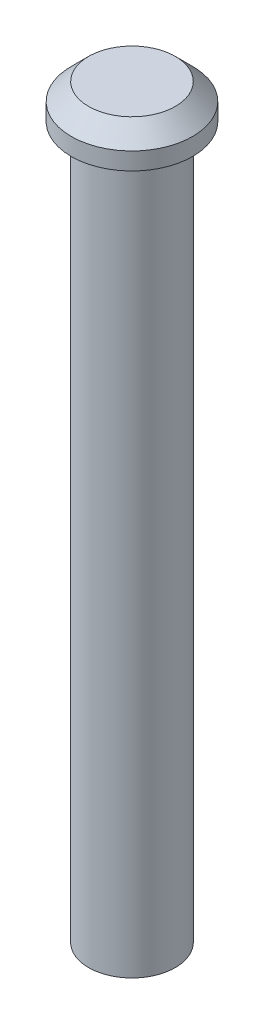
from build123d import *

# Parameters (mm, degrees)
SKETCH1_R           = 2.5
BOSS_EXTRUDE1_DEPTH = 41
SKETCH2_R           = 3.5
BOSS_EXTRUDE2_DEPTH = 2
CHAMFER1_SIZE       = 1
SKETCH3_R           = 1.5
CUT_EXTRUDE1_DEPTH  = 5


with BuildPart() as part:
    # Sketch1 → Boss-Extrude1 (new body)
    with BuildSketch(Plane(origin=(0, 0, 0), x_dir=(1, 0, 0), z_dir=(0, 1, 0))):
        Circle(SKETCH1_R)
    extrude(amount=BOSS_EXTRUDE1_DEPTH)

    # Sketch2 → Boss-Extrude2 (add)
    with BuildSketch(Plane(origin=(0, 41, 0), x_dir=(1, 0, 0), z_dir=(0, 1, 0))):
        Circle(SKETCH2_R)
    extrude(amount=BOSS_EXTRUDE2_DEPTH)

    # Chamfer1
    chamfer1_edges = [part.edges().sort_by_distance(p)[0] for p in [
        (-3.5, 43, 0),
    ]]
    chamfer(chamfer1_edges, length=CHAMFER1_SIZE)

    # Sketch3 → Cut-Extrude1 (cut)
    with BuildSketch(Plane.XZ):
        Circle(SKETCH3_R)
    extrude(amount=-CUT_EXTRUDE1_DEPTH, mode=Mode.SUBTRACT)


solid = part.part
